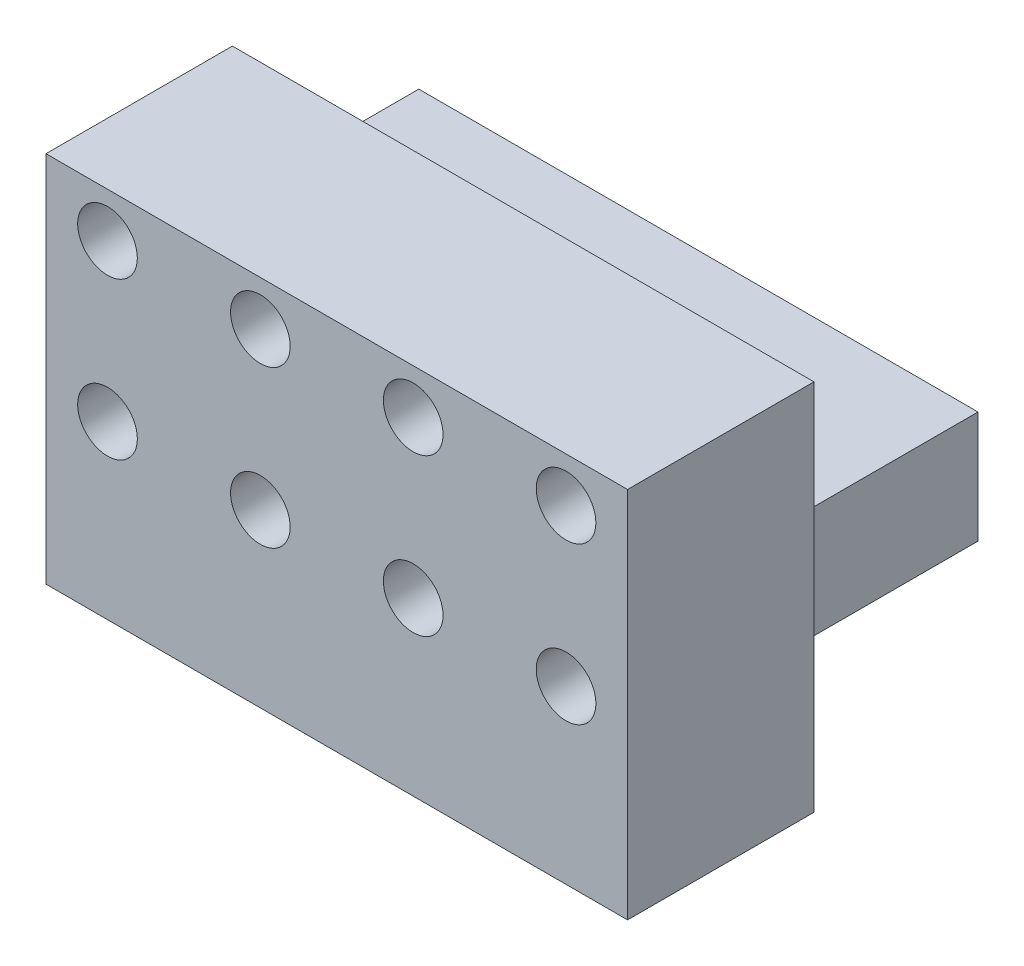
from build123d import *

# Parameters (mm, degrees)
SKETCH1_W           = 38.1
SKETCH1_H           = 7.62
BOSS_EXTRUDE1_DEPTH = 12.7
SKETCH2_W           = 39.624
SKETCH2_H           = 25.4
BOSS_EXTRUDE2_DEPTH = 12.7
SKETCH3_R           = 2.032
CUT_EXTRUDE1_DEPTH  = 7.62


with BuildPart() as part:
    # Sketch1 → Boss-Extrude1 (new body)
    with BuildSketch(Plane.XY):
        with Locations((-19.05, 3.81)):
            Rectangle(SKETCH1_W, SKETCH1_H)
    extrude(amount=BOSS_EXTRUDE1_DEPTH)

    # Sketch2 → Boss-Extrude2 (add)
    with BuildSketch(Plane.XY.offset(12.7)):
        with Locations((-18.288, 3.81)):
            Rectangle(SKETCH2_W, SKETCH2_H)
    extrude(amount=BOSS_EXTRUDE2_DEPTH)

    # Sketch3 → Cut-Extrude1 (cut)
    with BuildSketch(Plane.XY.offset(25.4)):
        with Locations((-33.909, 13.462)):
            Circle(SKETCH3_R)
        with Locations((-23.495, 13.462)):
            Circle(SKETCH3_R)
        with Locations((-2.667, 13.462)):
            Circle(SKETCH3_R)
        with Locations((-13.081, 2.794)):
            Circle(SKETCH3_R)
        with Locations((-23.495, 2.794)):
            Circle(SKETCH3_R)
        with Locations((-33.909, 2.794)):
            Circle(SKETCH3_R)
        with Locations((-13.081, 13.462)):
            Circle(SKETCH3_R)
        with Locations((-2.667, 2.794)):
            Circle(SKETCH3_R)
    extrude(amount=-CUT_EXTRUDE1_DEPTH, mode=Mode.SUBTRACT)


solid = part.part
